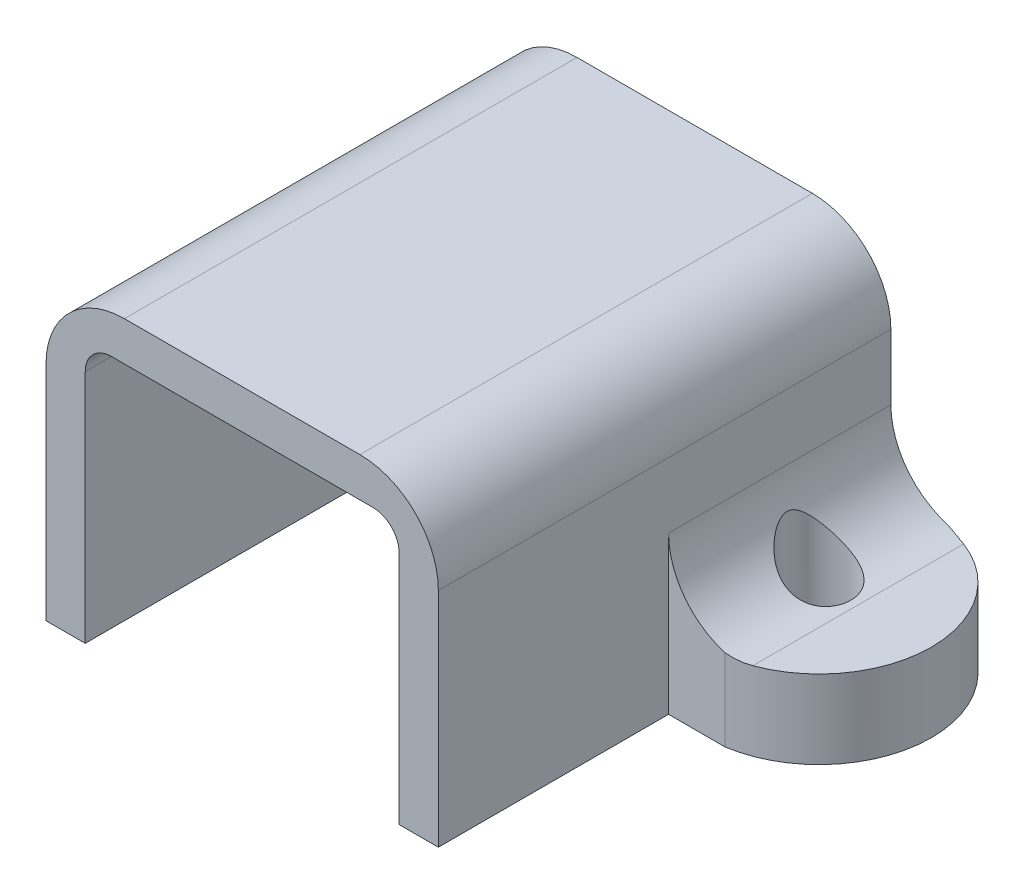
from build123d import *

# Parameters (mm, degrees)
EXTRUDE1_DEPTH            = 17.3
SKETCH2_W                 = 5.8
SKETCH2_H                 = 8.5
EXTRUDE2_DEPTH            = 8.8
SKETCH3_R                 = 1
EXTRUDE3_DEPTH            = 5
F_2_CLEARANCE_HOLE1_D     = 2.4384
F_2_CLEARANCE_HOLE1_DEPTH = 11.5


with BuildPart() as part:
    # Sketch1 → Extrude1 (new body)
    with BuildSketch(Plane.XY):
        with BuildLine():
            Line((-13.3, 0), (-6, 0))
            Line((-6, 0), (-6, 9))
            ThreePointArc((-6, 9), (-5.707106781, 9.707106781), (-5, 10))
            Line((-5, 10), (5, 10))
            ThreePointArc((5, 10), (5.707106781, 9.707106781), (6, 9))
            Line((6, 9), (6, 0))
            Line((6, 0), (13.3, 0))
            Line((13.3, 0), (13.3, 3))
            Line((13.3, 3), (10.5, 3))
            ThreePointArc((10.5, 3), (8.378679656, 3.878679656), (7.5, 6))
            Line((7.5, 6), (7.5, 8.5))
            ThreePointArc((7.5, 8.5), (6.621320344, 10.621320344), (4.5, 11.5))
            Line((4.5, 11.5), (-4.5, 11.5))
            ThreePointArc((-4.5, 11.5), (-6.621320344, 10.621320344), (-7.5, 8.5))
            Line((-7.5, 8.5), (-7.5, 6))
            ThreePointArc((-7.5, 6), (-8.378679656, 3.878679656), (-10.5, 3))
            Line((-10.5, 3), (-13.3, 3))
            Line((-13.3, 3), (-13.3, 0))
        make_face()
    extrude(amount=EXTRUDE1_DEPTH)

    # Sketch2 → Extrude2 (cut)
    with BuildSketch(Plane.XY.offset(17.3)):
        with Locations((-10.4, 4.25)):
            Rectangle(SKETCH2_W, SKETCH2_H)
        with Locations((10.4, 4.25)):
            Rectangle(SKETCH2_W, SKETCH2_H)
    extrude(amount=-EXTRUDE2_DEPTH, mode=Mode.SUBTRACT)

    # Sketch3 → Extrude3 (cut)
    with BuildSketch(Plane.XZ):
        with Locations(Location((-9, 4.25, 0), (0, 0, 270))):  # turned: the seam where the file's is
            Circle(SKETCH3_R)
        with Locations(Location((9, 4.25, 0), (0, 0, 270))):  # turned: the seam where the file's is
            Circle(SKETCH3_R)
        with BuildLine():
            Line((9.653834842, 8.5), (9.653834842, 9.262963398))
            Line((9.653834842, 9.262963398), (15.079268599, 9.262963398))
            Line((15.079268599, 9.262963398), (15.079268599, -0.486230121))
            Line((15.079268599, -0.486230121), (9.653834842, -0.486230121))
            Line((9.653834842, -0.486230121), (9.653834842, 0))
            ThreePointArc((9.653834842, 0), (13.3, 4.25), (9.653834842, 8.5))
        make_face()
        with BuildLine():
            Line((-9.653834842, -0.486230121), (-9.653834842, 0))
            ThreePointArc((-9.653834842, 0), (-13.3, 4.25), (-9.653834842, 8.5))
            Line((-9.653834842, 8.5), (-9.653834842, 9.262963398))
            Line((-9.653834842, 9.262963398), (-15.079268599, 9.262963398))
            Line((-15.079268599, 9.262963398), (-15.079268599, -0.486230121))
            Line((-15.079268599, -0.486230121), (-9.653834842, -0.486230121))
        make_face()
    extrude(amount=-EXTRUDE3_DEPTH, mode=Mode.SUBTRACT)

    # #2 Clearance Hole1
    with Locations(Plane(origin=(-9, 0, 4.25), x_dir=(0, 0, -1), z_dir=(0, -1, 0))):
        with Locations((0, 0), (0, 18)):
            Hole(F_2_CLEARANCE_HOLE1_D / 2, depth=F_2_CLEARANCE_HOLE1_DEPTH)


solid = part.part
